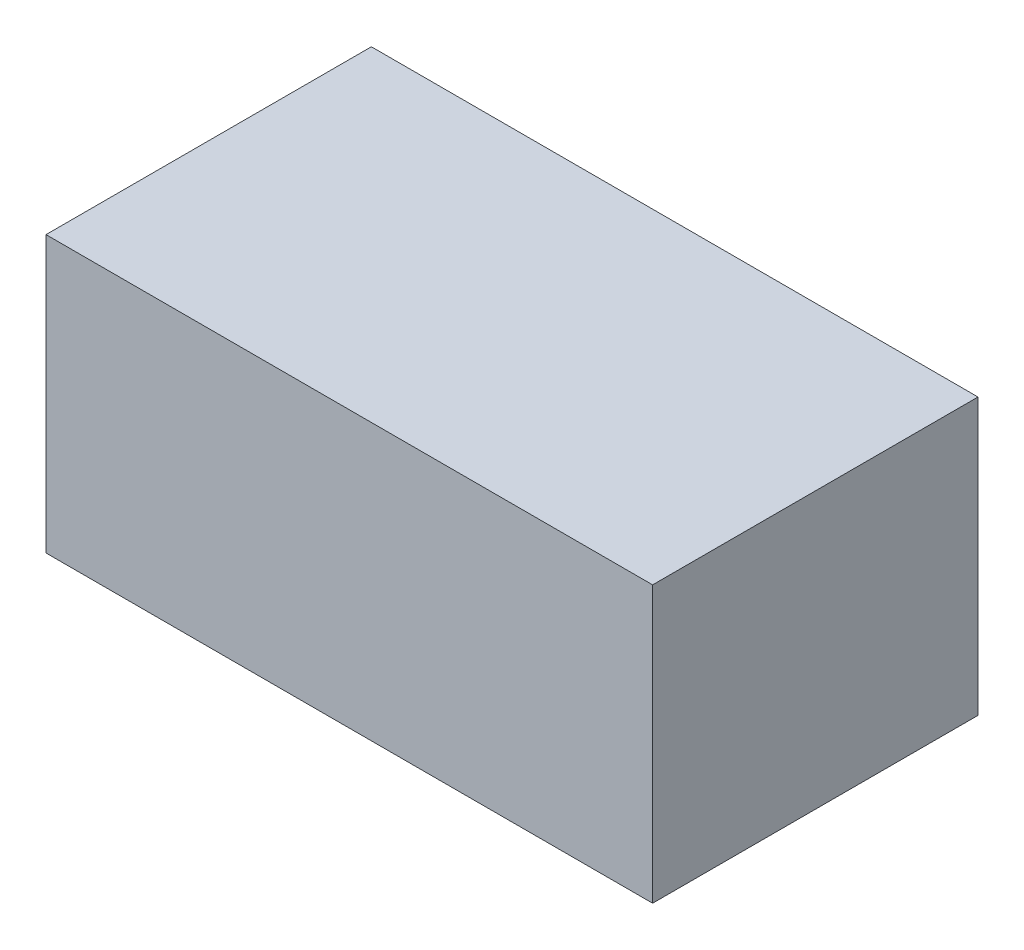
from build123d import *

# Parameters (mm, degrees)
SKETCH1_W      = 279.4
SKETCH1_H      = 127
EXTRUDE1_DEPTH = 149.86


with BuildPart() as part:
    # Sketch1 → Extrude1 (new body)
    with BuildSketch(Plane.XY):
        Rectangle(SKETCH1_W, SKETCH1_H)
    extrude(amount=EXTRUDE1_DEPTH)


solid = part.part
